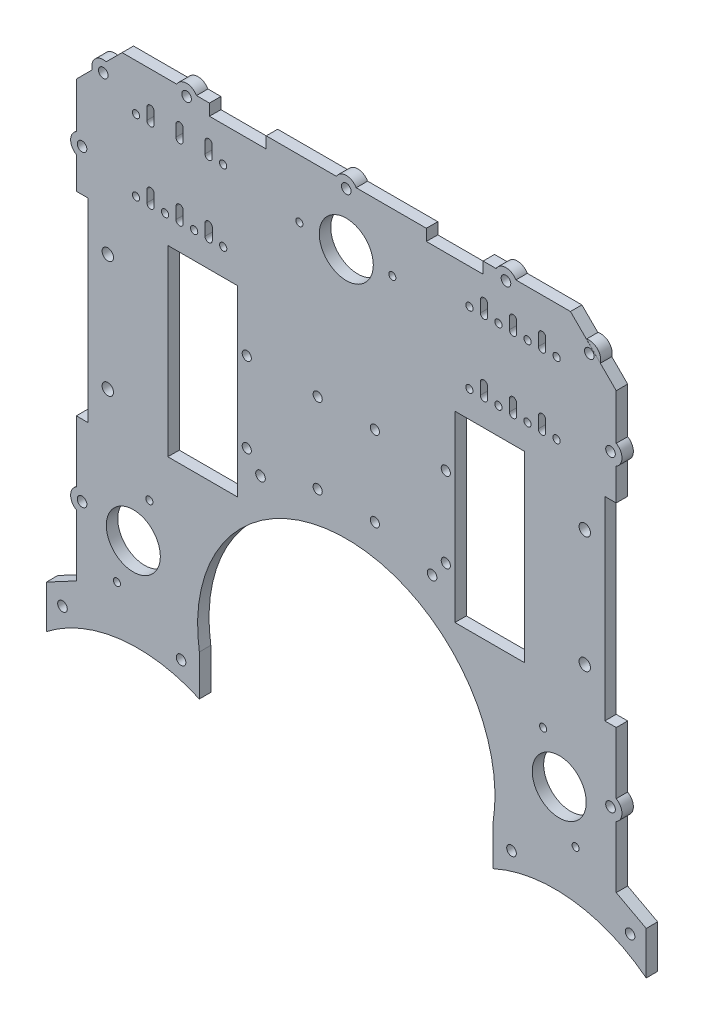
from build123d import *

# Parameters (mm, degrees)
SKETCH1_W           = 30.5
SKETCH1_H           = 80
BOSS_EXTRUDE1_DEPTH = 5
SKETCH2_R           = 2
CUT_EXTRUDE1_DEPTH  = 6
SKETCH3_R           = 11.807611308
SKETCH3_R_2         = 1.55
SKETCH3_R_3         = 1.5875
SKETCH3_R_4         = 2.5
CUT_EXTRUDE2_DEPTH  = 6
SKETCH4_W           = 5
SKETCH4_H           = 85
CUT_EXTRUDE3_DEPTH  = 6
SKETCH7_R           = 2.1
SKETCH7_W           = 24.8
SKETCH7_H           = 5
CUT_EXTRUDE5_DEPTH  = 6
BOSS_EXTRUDE3_DEPTH = 5
SKETCH9_R           = 2.1
CUT_EXTRUDE6_DEPTH  = 6
SKETCH10_R          = 2.1
CUT_EXTRUDE7_DEPTH  = 5
BOSS_EXTRUDE4_DEPTH = 5
BOSS_EXTRUDE5_DEPTH = 5
SKETCH13_R          = 2.1
CUT_EXTRUDE8_DEPTH  = 10


with BuildPart() as part:
    # Sketch1 → Boss-Extrude1 (new body)
    with BuildSketch(Plane.XY):
        with BuildLine():
            Line((64.226162893, -107), (118, -107))
            Line((118, -107), (118, 83))
            Line((118, 83), (98, 103))
            Line((98, 103), (-98, 103))
            Line((-98, 103), (-118, 83))
            Line((-118, 83), (-118, -107))
            Line((-118, -107), (-64.226162893, -107))
            ThreePointArc((-64.226162893, -107), (0, -32), (64.226162893, -107))
        make_face()
        with Locations((62.75, 0)):
            Rectangle(SKETCH1_W, SKETCH1_H, mode=Mode.SUBTRACT)
        with Locations((-62.75, 0)):
            Rectangle(SKETCH1_W, SKETCH1_H, mode=Mode.SUBTRACT)
    extrude(amount=BOSS_EXTRUDE1_DEPTH)

    # Sketch2 → Cut-Extrude1 (cut, through all)
    with BuildSketch(Plane.XY.offset(5)):
        with Locations((43.5, 15.5)):
            Circle(SKETCH2_R)
        with Locations((43.5, -19.5)):
            Circle(SKETCH2_R)
        with Locations((12.5, -19.5)):
            Circle(SKETCH2_R)
        with Locations((12.5, 15.5)):
            Circle(SKETCH2_R)
        with Locations((-12.5, 15.5)):
            Circle(SKETCH2_R)
        with Locations((-12.5, -19.5)):
            Circle(SKETCH2_R)
        with Locations((-43.5, -19.5)):
            Circle(SKETCH2_R)
        with Locations((-43.5, 15.5)):
            Circle(SKETCH2_R)
    extrude(amount=-CUT_EXTRUDE1_DEPTH, mode=Mode.SUBTRACT)

    # Sketch3 → Cut-Extrude2 (cut, through all)
    with BuildSketch(Plane.XY.offset(5)):
        with Locations((0, 77.5)):
            Circle(SKETCH3_R)
        with Locations((20.138291871, 77.5)):
            Circle(SKETCH3_R_2)
        with Locations((-20.503494055, 77.5)):
            Circle(SKETCH3_R_2)
        with BuildLine():
            Line((-71.2975, 87.747), (-71.3, 82.747))
            ThreePointArc((-71.3, 82.747), (-72.8875, 81.1595), (-74.475, 82.747))
            Line((-74.475, 82.747), (-74.4775, 87.747))
            ThreePointArc((-74.4775, 87.747), (-72.8875, 89.337), (-71.2975, 87.747))
        make_face()
        with BuildLine():
            Line((-58.5975, 87.747), (-58.6, 82.747))
            ThreePointArc((-58.6, 82.747), (-60.1875, 81.1595), (-61.775, 82.747))
            Line((-61.775, 82.747), (-61.7775, 87.747))
            ThreePointArc((-61.7775, 87.747), (-60.1875, 89.337), (-58.5975, 87.747))
        make_face()
        with BuildLine():
            ThreePointArc((-87.175, 87.747), (-85.5875, 89.3345), (-84, 87.747))
            Line((-84, 87.747), (-84, 82.747))
            ThreePointArc((-84, 82.747), (-85.5875, 81.1595), (-87.175, 82.747))
            Line((-87.175, 82.747), (-87.175, 87.747))
        make_face()
        with Locations((-91.9375, 82.747)):
            Circle(SKETCH3_R_3)
        with Locations((-91.910884632, 51.582790513)):
            Circle(SKETCH3_R_3)
        with BuildLine():
            Line((-87.148384632, 56.582790513), (-87.148384632, 51.582790513))
            ThreePointArc((-87.148384632, 51.582790513), (-85.560884632, 49.995290513), (-83.973384632, 51.582790513))
            Line((-83.973384632, 51.582790513), (-83.973384632, 56.582790513))
            ThreePointArc((-83.973384632, 56.582790513), (-85.560884632, 58.170290513), (-87.148384632, 56.582790513))
        make_face()
        with BuildLine():
            Line((-74.450884632, 56.582790513), (-74.448384632, 51.582790513))
            ThreePointArc((-74.448384632, 51.582790513), (-72.860884632, 49.995290513), (-71.273384632, 51.582790513))
            Line((-71.273384632, 51.582790513), (-71.270884632, 56.582790513))
            ThreePointArc((-71.270884632, 56.582790513), (-72.860884632, 58.172790513), (-74.450884632, 56.582790513))
        make_face()
        with Locations((-79.210884632, 51.582790513)):
            Circle(SKETCH3_R_3)
        with BuildLine():
            Line((-61.750884632, 56.582790513), (-61.748384632, 51.582790513))
            ThreePointArc((-61.748384632, 51.582790513), (-60.160884632, 49.995290513), (-58.573384632, 51.582790513))
            Line((-58.573384632, 51.582790513), (-58.570884632, 56.582790513))
            ThreePointArc((-58.570884632, 56.582790513), (-60.160884632, 58.172790513), (-61.750884632, 56.582790513))
        make_face()
        with Locations((-66.510884632, 51.582790513)):
            Circle(SKETCH3_R_3)
        with Locations((-53.810884632, 51.582790513)):
            Circle(SKETCH3_R_3)
        with BuildLine():
            ThreePointArc((87.175, 82.747), (85.5875, 81.1595), (84, 82.747))
            Line((84, 82.747), (84, 87.747))
            ThreePointArc((84, 87.747), (85.5875, 89.3345), (87.175, 87.747))
            Line((87.175, 87.747), (87.175, 82.747))
        make_face()
        with Locations((79.2375, 82.747)):
            Circle(SKETCH3_R_3)
        with BuildLine():
            ThreePointArc((74.475, 82.747), (72.8875, 81.1595), (71.3, 82.747))
            Line((71.3, 82.747), (71.2975, 87.747))
            ThreePointArc((71.2975, 87.747), (72.8875, 89.337), (74.4775, 87.747))
            Line((74.4775, 87.747), (74.475, 82.747))
        make_face()
        with BuildLine():
            ThreePointArc((58.5975, 87.747), (60.1875, 89.337), (61.7775, 87.747))
            Line((61.7775, 87.747), (61.775, 82.747))
            ThreePointArc((61.775, 82.747), (60.1875, 81.1595), (58.6, 82.747))
            Line((58.6, 82.747), (58.5975, 87.747))
        make_face()
        with Locations((53.8375, 82.747)):
            Circle(SKETCH3_R_3)
        with Locations((66.5375, 82.747)):
            Circle(SKETCH3_R_3)
        with Locations((91.9375, 82.747)):
            Circle(SKETCH3_R_3)
        with BuildLine():
            Line((87.148384632, 56.582790513), (87.148384632, 51.582790513))
            ThreePointArc((87.148384632, 51.582790513), (85.560884632, 49.995290513), (83.973384632, 51.582790513))
            Line((83.973384632, 51.582790513), (83.973384632, 56.582790513))
            ThreePointArc((83.973384632, 56.582790513), (85.560884632, 58.170290513), (87.148384632, 56.582790513))
        make_face()
        with Locations((91.910884632, 51.582790513)):
            Circle(SKETCH3_R_3)
        with Locations((79.210884632, 51.582790513)):
            Circle(SKETCH3_R_3)
        with BuildLine():
            ThreePointArc((71.270884632, 56.582790513), (72.860884632, 58.172790513), (74.450884632, 56.582790513))
            Line((74.450884632, 56.582790513), (74.448384632, 51.582790513))
            ThreePointArc((74.448384632, 51.582790513), (72.860884632, 49.995290513), (71.273384632, 51.582790513))
            Line((71.273384632, 51.582790513), (71.270884632, 56.582790513))
        make_face()
        with Locations((66.510884632, 51.582790513)):
            Circle(SKETCH3_R_3)
        with BuildLine():
            ThreePointArc((58.570884632, 56.582790513), (60.160884632, 58.172790513), (61.750884632, 56.582790513))
            Line((61.750884632, 56.582790513), (61.748384632, 51.582790513))
            ThreePointArc((61.748384632, 51.582790513), (60.160884632, 49.995290513), (58.573384632, 51.582790513))
            Line((58.573384632, 51.582790513), (58.570884632, 56.582790513))
        make_face()
        with Locations((53.810884632, 51.582790513)):
            Circle(SKETCH3_R_3)
        with Locations((104.25, 23.5)):
            Circle(SKETCH3_R_4)
        with Locations((104.25, -27.5)):
            Circle(SKETCH3_R_4)
        with Locations((93.092103794, -79.3816003)):
            Circle(SKETCH3_R)
        with Locations((86.056787146, -60.512177438)):
            Circle(SKETCH3_R_2)
        with Locations((100.255003904, -98.593214768)):
            Circle(SKETCH3_R_2)
        with Locations((-104.25, 23.5)):
            Circle(SKETCH3_R_4)
        with Locations((-104.25, -27.5)):
            Circle(SKETCH3_R_4)
        with Locations((-93.092103794, -79.3816003)):
            Circle(SKETCH3_R)
        with Locations((-100.255003904, -98.593214768)):
            Circle(SKETCH3_R_2)
        with Locations((-86.056787146, -60.512177438)):
            Circle(SKETCH3_R_2)
        with Locations((-53.8375, 82.747)):
            Circle(SKETCH3_R_3)
    extrude(amount=-CUT_EXTRUDE2_DEPTH, mode=Mode.SUBTRACT)

    # Sketch4 → Cut-Extrude3 (cut, through all)
    with BuildSketch(Plane.XY.offset(5)):
        with Locations((-115.5, -2)):
            Rectangle(SKETCH4_W, SKETCH4_H)
        with Locations((115.5, -2)):
            Rectangle(SKETCH4_W, SKETCH4_H)
    extrude(amount=-CUT_EXTRUDE3_DEPTH, mode=Mode.SUBTRACT)

    # Sketch7 → Cut-Extrude5 (cut, through all)
    with BuildSketch(Plane(origin=(0, 0, 0), x_dir=(-1, 0, 0), z_dir=(0, 0, -1))):
        with Locations((0, 100.5)):
            Circle(SKETCH7_R)
        with Locations((69.8, 100.5)):
            Circle(SKETCH7_R)
        with Locations((-69.8, 100.5)):
            Circle(SKETCH7_R)
        with Locations((-47.4, 100.5)):
            Rectangle(SKETCH7_W, SKETCH7_H)
        with Locations((47.4, 100.5)):
            Rectangle(SKETCH7_W, SKETCH7_H)
    extrude(amount=-CUT_EXTRUDE5_DEPTH, mode=Mode.SUBTRACT)

    # Sketch8 → Boss-Extrude3 (add)
    with BuildSketch(Plane(origin=(0, 0, 0), x_dir=(-1, 0, 0), z_dir=(0, 0, -1))):
        with BuildLine():
            Line((-74.130127019, 103), (-65.469872981, 103))
            ThreePointArc((-65.469872981, 103), (-69.8, 105.5), (-74.130127019, 103))
        make_face()
        with BuildLine():
            Line((-4.330127019, 103), (4.330127019, 103))
            ThreePointArc((4.330127019, 103), (0, 105.5), (-4.330127019, 103))
        make_face()
        with BuildLine():
            Line((65.469872981, 103), (74.130127019, 103))
            ThreePointArc((74.130127019, 103), (69.8, 105.5), (65.469872981, 103))
        make_face()
    extrude(amount=-BOSS_EXTRUDE3_DEPTH)

    # Sketch9 → Cut-Extrude6 (cut, through all)
    with BuildSketch(Plane.XY.offset(5)):
        with Locations((37.5, -27)):
            Circle(SKETCH9_R)
        with Locations((-37.5, -27)):
            Circle(SKETCH9_R)
    extrude(amount=-CUT_EXTRUDE6_DEPTH, mode=Mode.SUBTRACT)

    # Sketch10 → Cut-Extrude7 (cut)
    with BuildSketch(Plane(origin=(0, 0, 0), x_dir=(-1, 0, 0), z_dir=(0, 0, -1))):
        with Locations((-115.5, -75.75)):
            Circle(SKETCH10_R)
        with Locations((115.5, -75.75)):
            Circle(SKETCH10_R)
        with Locations((-115.5, 58.75)):
            Circle(SKETCH10_R)
        with Locations((115.5, 58.75)):
            Circle(SKETCH10_R)
        with Locations((-106.232988104, 91.23147799)):
            Circle(SKETCH10_R)
        with Locations((106.232988104, 91.23147799)):
            Circle(SKETCH10_R)
    extrude(amount=-CUT_EXTRUDE7_DEPTH, mode=Mode.SUBTRACT)

    # Sketch11 → Boss-Extrude4 (add)
    with BuildSketch(Plane(origin=(0, 0, 0), x_dir=(-1, 0, 0), z_dir=(0, 0, -1))):
        with BuildLine():
            Line((-118, 54.419872981), (-118, 63.080127019))
            ThreePointArc((-118, 63.080127019), (-120.5, 58.75), (-118, 54.419872981))
        make_face()
        with BuildLine():
            Line((-118, -71.419872981), (-118, -80.080127019))
            ThreePointArc((-118, -80.080127019), (-120.5, -75.75), (-118, -71.419872981))
        make_face()
        with BuildLine():
            Line((118, -71.419872981), (118, -80.080127019))
            ThreePointArc((118, -80.080127019), (120.5, -75.75), (118, -71.419872981))
        make_face()
        with BuildLine():
            Line((118, 63.080127019), (118, 54.419872981))
            ThreePointArc((118, 54.419872981), (120.5, 58.75), (118, 63.080127019))
        make_face()
        with BuildLine():
            Line((104.938892879, 96.061107121), (111.062617235, 89.937382765))
            ThreePointArc((111.062617235, 89.937382765), (109.76852201, 94.767011896), (104.938892879, 96.061107121))
        make_face()
        with BuildLine():
            Line((-104.999243157, 96.076875126), (-111.062617235, 89.937382765))
            ThreePointArc((-111.062617235, 89.937382765), (-109.790506534, 94.74488981), (-104.999243157, 96.076875126))
        make_face()
    extrude(amount=-BOSS_EXTRUDE4_DEPTH)

    # Sketch12 → Boss-Extrude5 (add)
    with BuildSketch(Plane(origin=(0, 0, 0), x_dir=(-1, 0, 0), z_dir=(0, 0, -1))):
        with BuildLine():
            Line((-118, -107), (-131.113081447, -114))
            Line((-131.113081447, -114), (-131.113081447, -132.76524617))
            ThreePointArc((-131.113081447, -132.76524617), (-98.778846905, -119.45361327), (-64.226162893, -124.821510574))
            Line((-64.226162893, -124.821510574), (-64.226162893, -107))
            Line((-64.226162893, -107), (-118, -107))
        make_face()
        with BuildLine():
            Line((118, -107), (64.226162893, -107))
            Line((64.226162893, -107), (64.226162893, -124.821510574))
            ThreePointArc((64.226162893, -124.821510574), (98.778846905, -119.45361327), (131.113081447, -132.76524617))
            Line((131.113081447, -132.76524617), (131.113081447, -114))
            Line((131.113081447, -114), (118, -107))
        make_face()
    extrude(amount=-BOSS_EXTRUDE5_DEPTH)

    # Sketch13 → Cut-Extrude8 (cut)
    with BuildSketch(Plane(origin=(0, 0, 0), x_dir=(-1, 0, 0), z_dir=(0, 0, -1))):
        with Locations((-72.228081447, -114)):
            Circle(SKETCH13_R)
        with Locations((-124.055449987, -119.615682924)):
            Circle(SKETCH13_R)
        with Locations((124.055449987, -119.615682924)):
            Circle(SKETCH13_R)
        with Locations((72.228081447, -114)):
            Circle(SKETCH13_R)
    extrude(amount=-CUT_EXTRUDE8_DEPTH, mode=Mode.SUBTRACT)


solid = part.part
